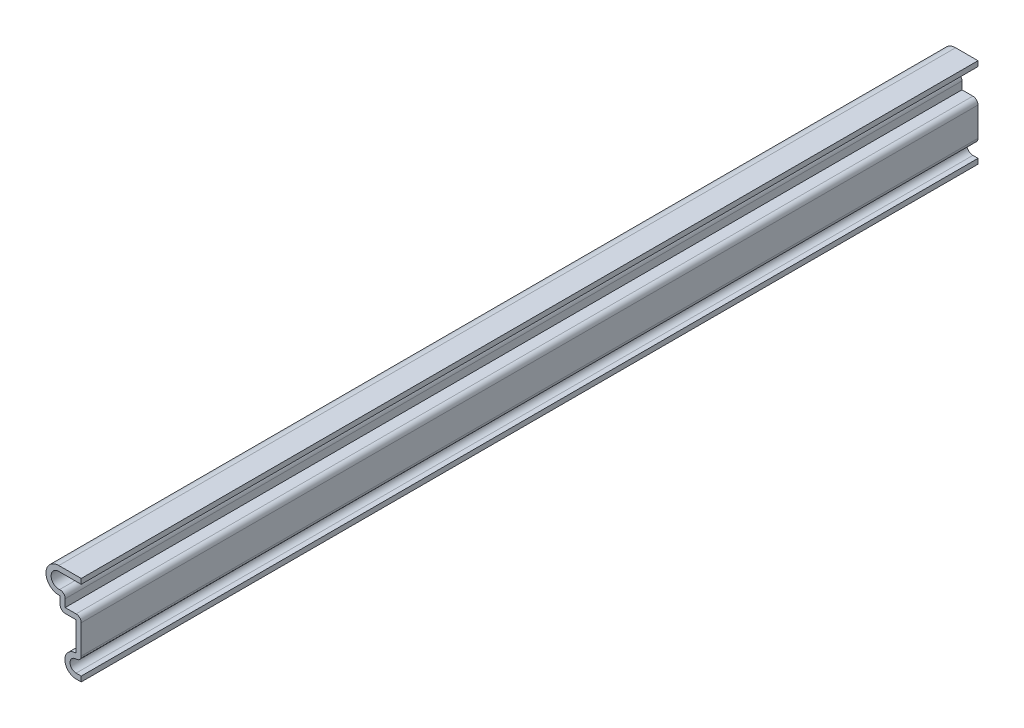
from build123d import *

# Parameters (mm, degrees)
EXTRUDE_THIN2_DEPTH = 222.25
FILLET1_R           = 1.27


with BuildPart() as part:
    # Sketch1 → Extrude-Thin2 (new body)
    with BuildSketch(Plane.XY):
        with BuildLine():
            Line((0, 22.225), (-5.55625, 22.225))
            ThreePointArc((-5.55625, 22.225), (-8.727268782, 18.891050689), (-5.23875, 15.890914887))
            Line((-5.23875, 15.890914887), (-5.23875, 12.715914887))
            Line((-5.23875, 12.715914887), (-1.27, 12.715914887))
            Line((-1.27, 12.715914887), (-1.27, 5.55625))
            ThreePointArc((-1.27, 5.55625), (-4.048125, 2.778125), (-1.27, 0))
            Line((-1.27, 0), (0, 0))
            Line((0, 0), (0, 1.27))
            Line((0, 1.27), (-1.27, 1.27))
            ThreePointArc((-1.27, 1.27), (-2.593079188, 3.501936079), (0, 3.591476717))
            Line((0, 3.591476717), (0, 13.985914887))
            Line((0, 13.985914887), (-3.96875, 13.985914887))
            Line((-3.96875, 13.985914887), (-3.96875, 17.996971629))
            ThreePointArc((-3.96875, 17.996971629), (-7.234797593, 18.1491654), (-5.55625, 20.955))
            Line((-5.55625, 20.955), (0, 20.955))
            Line((0, 20.955), (0, 22.225))
        make_face()
    extrude(amount=-EXTRUDE_THIN2_DEPTH)

    # Fillet1
    fillet1_edges = [part.edges().sort_by_distance(p)[0] for p in [
        (-5.23875, 12.715914887, -111.125),
        (-3.96875, 17.996971629, -111.125),
        (0, 13.985914887, -111.125),
        (0, 3.591476717, -111.125),
    ]]
    fillet(fillet1_edges, radius=FILLET1_R)


solid = part.part
